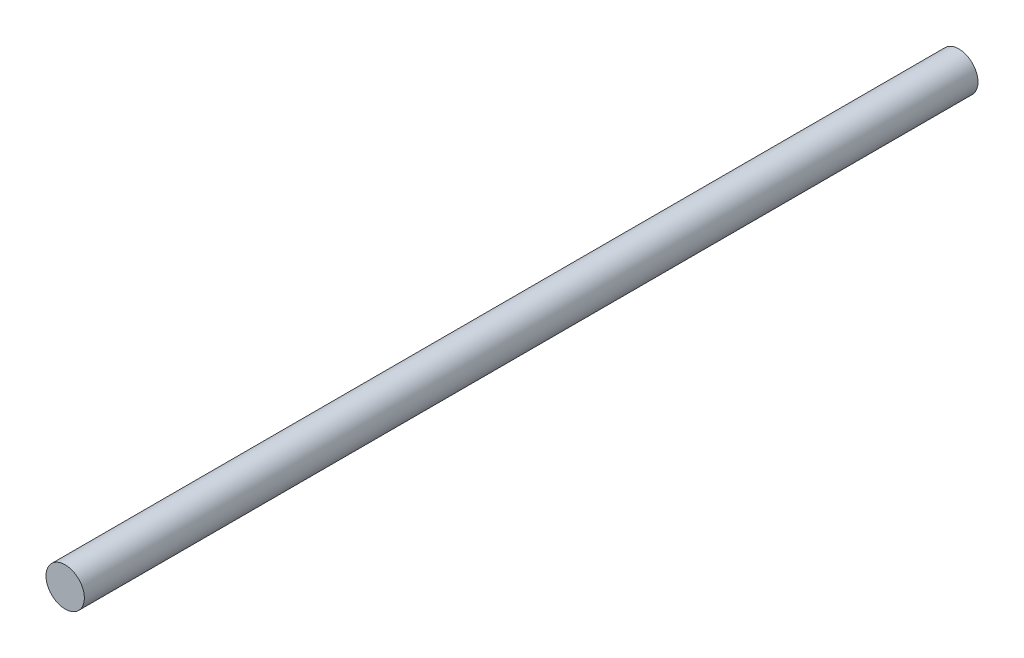
from build123d import *

# Parameters (mm, degrees)
SKETCH_1_R      = 10.75
EXTRUDE_1_DEPTH = 500.5


with BuildPart() as part:
    # Эскиз1 → Бобышка-Вытянуть1 (new body)
    with BuildSketch(Plane.XY):
        Circle(SKETCH_1_R)
    extrude(amount=EXTRUDE_1_DEPTH)


solid = part.part
